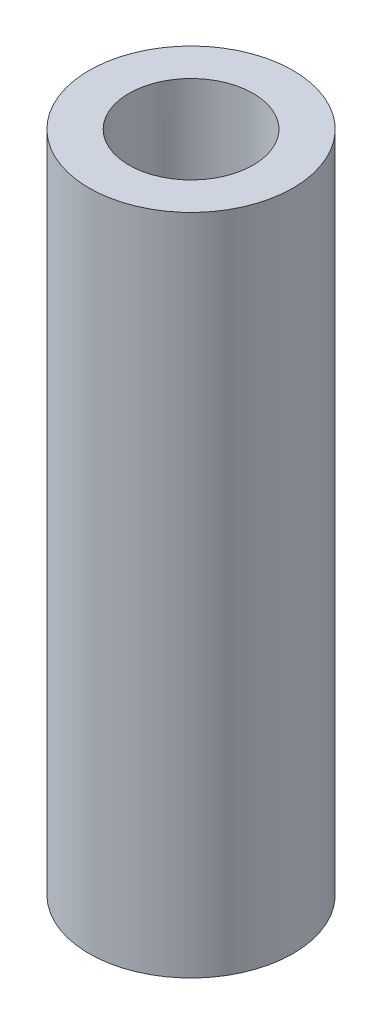
from build123d import *

# Parameters (mm, degrees)
SKETCH2_W               = 7.8105
SKETCH2_H               = 3.90525
CUT_EXTRUDE1_DEPTH      = 4.90525
CUT_EXTRUDE1_DEPTH_BACK = 4.90525


with BuildPart() as part:
    # Sketch1 → Revolve1 (revolve)
    with BuildSketch(Plane.XY):
        with BuildLine():
            Line((2.38125, 25.4), (2.38125, 0))
            Line((2.38125, 0), (3.90525, 0))
            Line((3.90525, 0), (3.90525, 25.4))
            ThreePointArc((3.90525, 25.4), (2.761428757, 28.161428757), (0, 29.30525))
            Line((0, 29.30525), (0, 27.78125))
            ThreePointArc((0, 27.78125), (1.683798023, 27.083798023), (2.38125, 25.4))
        make_face()
    revolve(axis=Axis((0, 0, 0), (0, 1, 0)))

    # Sketch2 → Cut-Extrude1 (cut, two sides)
    with BuildSketch(Plane.XY) as cut_extrude1_sk:
        with Locations((0, 27.352625)):
            Rectangle(SKETCH2_W, SKETCH2_H)
    extrude(amount=CUT_EXTRUDE1_DEPTH, mode=Mode.SUBTRACT)
    extrude(cut_extrude1_sk.sketch, amount=-CUT_EXTRUDE1_DEPTH_BACK, mode=Mode.SUBTRACT)


solid = part.part
